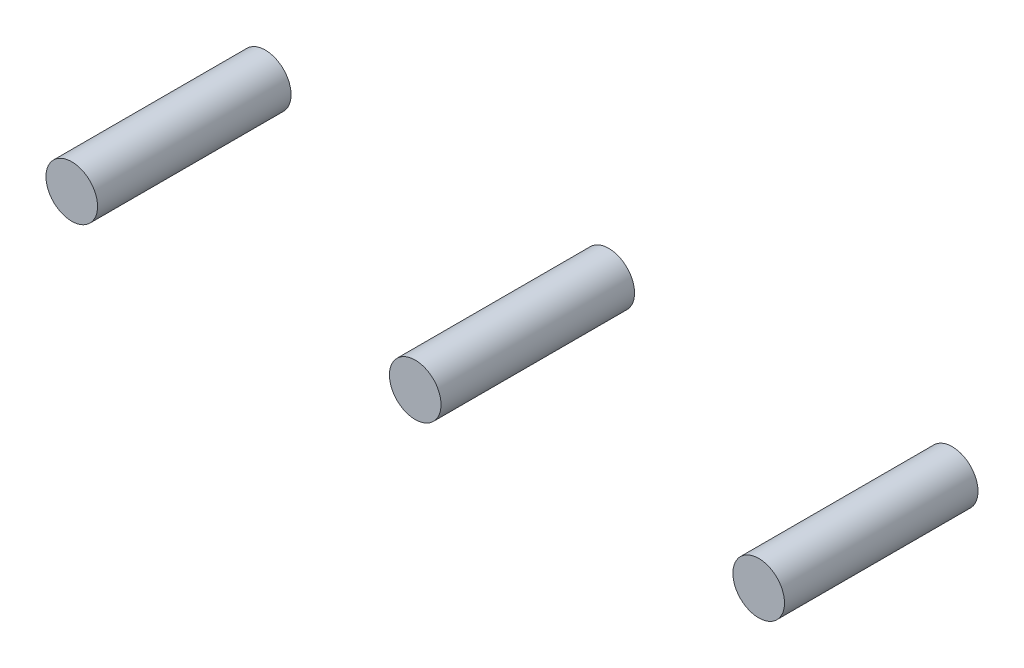
from build123d import *

# Parameters (mm, degrees)
SKETCH1_R        = 0.4
EXTRUDE1_DEPTH   = 3
EXTRUDE1_2_DEPTH = 3
EXTRUDE1_3_DEPTH = 3


with BuildPart() as part:
    # Sketch1 → Extrude1 (new body)
    with BuildSketch(Plane.XY):
        with Locations((0, 2.875)):
            Circle(SKETCH1_R)
    extrude(amount=EXTRUDE1_DEPTH)


with BuildPart() as body_2:
    # Sketch1 → Extrude1 2 (new body)
    with BuildSketch(Plane.XY):
        with Locations((-5.325, 2.875)):
            Circle(SKETCH1_R)
    extrude(amount=EXTRUDE1_2_DEPTH)


with BuildPart() as body_3:
    # Sketch1 → Extrude1 3 (new body)
    with BuildSketch(Plane.XY):
        with Locations((5.325, 2.875)):
            Circle(SKETCH1_R)
    extrude(amount=EXTRUDE1_3_DEPTH)


solid = Compound([part.part, body_2.part, body_3.part])
